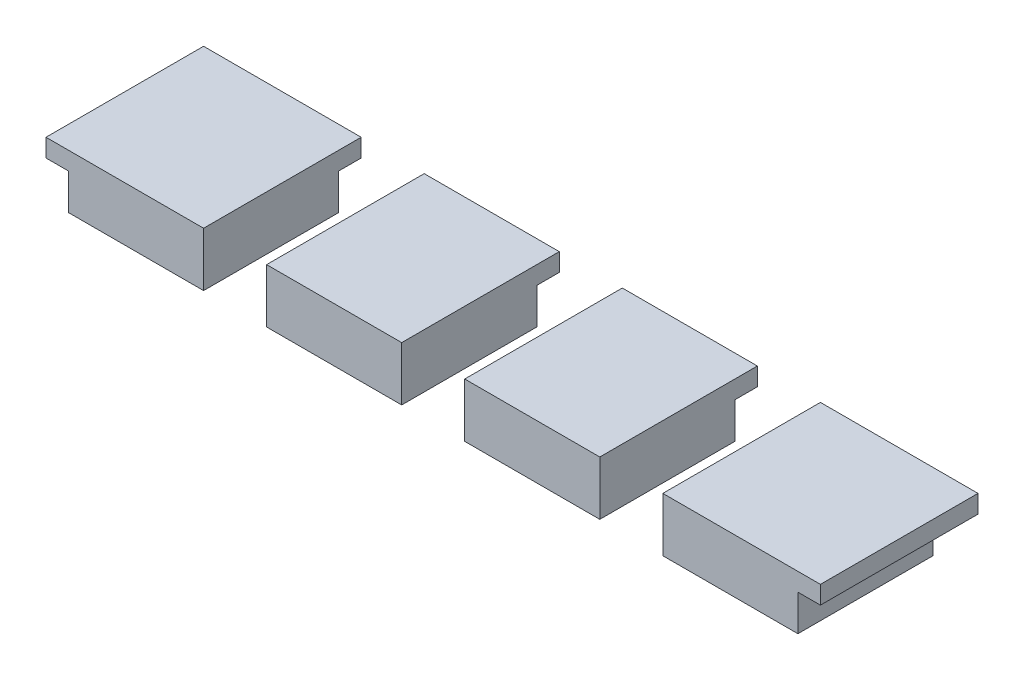
from build123d import *
from build123d.topology import SkipClean

# Parameters (mm, degrees)
SKETCH1_W                 = 78.1
SKETCH1_H                 = 55.9
BOSS_EXTRUDE1_DEPTH       = 3
SKETCH2_R                 = 1.25
CUT_EXTRUDE1_DEPTH        = 68
SKETCH4_W                 = 82.1
SKETCH4_H                 = 59.9
SKETCH4_W_2               = 78.1
SKETCH4_H_2               = 55.9
BOSS_EXTRUDE3_DEPTH       = 3
SKETCH6_R                 = 3
SKETCH6_R_2               = 1.25
BOSS_EXTRUDE4_DEPTH       = 3.5
SKETCH7_W                 = 82.1
SKETCH7_H                 = 16.2
BOSS_EXTRUDE5_DEPTH       = 3
SKETCH8_W                 = 82.1
SKETCH8_H                 = 50.5
BOSS_EXTRUDE6_DEPTH       = 3
SKETCH10_W                = 76.1
SKETCH10_H                = 3
BOSS_EXTRUDE7_DEPTH       = 20
SKETCH12_W                = 79.1
SKETCH12_H                = 50.5
BOSS_EXTRUDE8_DEPTH       = 3
SKETCH17_W                = 105.1
SKETCH17_H                = 50.5
BOSS_EXTRUDE13_DEPTH      = 1
BOSS_EXTRUDE13_DEPTH_BACK = 2
SKETCH18_W                = 11.5
SKETCH18_H                = 7.7
SKETCH18_W_2              = 39.6
SKETCH18_H_2              = 9
CUT_EXTRUDE4_DEPTH        = 9
SKETCH19_W                = 80.1
SKETCH19_H                = 50.5
BOSS_EXTRUDE14_DEPTH      = 3
SKETCH20_R                = 19
SKETCH20_R_2              = 1.5
CUT_EXTRUDE5_DEPTH        = 3
SKETCH22_R                = 2.5
CUT_EXTRUDE6_DEPTH        = 3
SKETCH23_R                = 1.5
BOSS_EXTRUDE16_DEPTH      = 3
SKETCH25_W                = 108.1
SKETCH25_H                = 50.5
CUT_EXTRUDE8_DEPTH        = 0.5
SKETCH26_W                = 79.6
SKETCH26_H                = 50.5
CUT_EXTRUDE9_DEPTH        = 0.5
SKETCH27_W                = 107.6
SKETCH27_H                = 50.5
CUT_EXTRUDE10_DEPTH       = 0.5
SKETCH28_W                = 79.1
SKETCH28_H                = 50.5
CUT_EXTRUDE11_DEPTH       = 0.5
SKETCH30_W                = 101.1
SKETCH30_H                = 73.1
BOSS_EXTRUDE17_DEPTH      = 2
BOSS_EXTRUDE17_DEPTH_BACK = 6
SKETCH31_W                = 39.6
SKETCH31_H                = 15.2
CUT_EXTRUDE12_DEPTH       = 18
SKETCH32_R                = 4
CUT_EXTRUDE13_DEPTH       = 788
SKETCH35_W                = 128.237297138
SKETCH35_H                = 101.417338931
CUT_EXTRUDE16_DEPTH       = 109
SKETCH36_W                = 107.1
SKETCH36_H                = 79.1
SKETCH36_W_2              = 102.1
SKETCH36_H_2              = 74.1
BOSS_EXTRUDE18_DEPTH      = 2
SKETCH37_W                = 107.1
SKETCH37_H                = 79.1
SKETCH37_W_2              = 102.1
SKETCH37_H_2              = 74.1
CUT_EXTRUDE17_DEPTH       = 6
SKETCH38_W                = 102.1
SKETCH38_H                = 74.1
SKETCH38_W_2              = 42.302719986
SKETCH38_H_2              = 18.764227688
BOSS_EXTRUDE19_DEPTH      = 2
SKETCH39_W                = 98.1
SKETCH39_H                = 70.1
CUT_EXTRUDE18_DEPTH       = 6
SKETCH40_R                = 4
BOSS_EXTRUDE21_DEPTH      = 20
SKETCH43_W                = 43.5
SKETCH43_H                = 1.5
CUT_EXTRUDE19_DEPTH       = 20
SKETCH44_W                = 22
SKETCH44_H                = 1.5
CUT_EXTRUDE20_DEPTH       = 20
FILLET1_R                 = 3
SKETCH45_W                = 73.258832398
SKETCH45_H                = 44.668177242
CUT_EXTRUDE21_DEPTH       = 63
CUT_EXTRUDE22_DEPTH       = 380
CUT_EXTRUDE22_DEPTH_BACK  = 374
BOSS_EXTRUDE23_DEPTH      = 2
SKETCH50_R                = 4
BOSS_EXTRUDE24_DEPTH      = 23
FILLET2_R                 = 3
SKETCH51_W                = 22
SKETCH51_H                = 0.5
CUT_EXTRUDE23_DEPTH       = 23
SKETCH52_W                = 22
SKETCH52_H                = 0.5
CUT_EXTRUDE24_DEPTH       = 23
SKETCH53_W                = 8
SKETCH53_H                = 8
CUT_EXTRUDE25_DEPTH       = 23
CUT_EXTRUDE26_DEPTH       = 23
SKETCH56_W                = 3.4
SKETCH56_H                = 1.5
SKETCH56_H_2              = 8
BOSS_EXTRUDE25_DEPTH      = 6
SKETCH58_W                = 4.9
SKETCH58_H                = 11
BOSS_EXTRUDE26_DEPTH      = 6
SKETCH61_R                = 1
CUT_EXTRUDE27_DEPTH       = 6
SKETCH62_W                = 3.4
SKETCH62_H                = 15.6
BOSS_EXTRUDE27_DEPTH      = 6
SKETCH64_W                = 4.9
SKETCH64_H                = 11
SKETCH64_R                = 1
SKETCH64_W_2              = 1.5
SKETCH64_H_2              = 70.1
BOSS_EXTRUDE28_DEPTH      = 2
BOSS_EXTRUDE29_DEPTH      = 8
SKETCH67_W                = 107.1
SKETCH67_H                = 79.1
SKETCH67_R                = 4
SKETCH67_W_2              = 8
SKETCH67_H_2              = 8
BOSS_EXTRUDE30_DEPTH      = 22
SKETCH68_W                = 8.1
SKETCH68_H                = 59.1
CUT_EXTRUDE28_DEPTH       = 22
SKETCH70_R                = 1.25
CUT_EXTRUDE29_DEPTH       = 22
SKETCH71_W                = 63
SKETCH71_H                = 13
CUT_EXTRUDE30_DEPTH       = 22
SKETCH72_W                = 72.2
SKETCH72_H                = 25
CUT_EXTRUDE31_DEPTH       = 1
SKETCH73_R                = 2.930769111
SKETCH73_R_2              = 1.25
SKETCH73_R_3              = 2.93
SKETCH73_W                = 75
SKETCH73_H                = 27.649527195
SKETCH73_W_2              = 72.2
SKETCH73_H_2              = 25
BOSS_EXTRUDE31_DEPTH      = 3
SKETCH74_R                = 2.93
SKETCH74_R_2              = 1.25
SKETCH74_R_3              = 2.930769111
BOSS_EXTRUDE32_DEPTH      = 3.5
SKETCH75_W                = 41
SKETCH75_H                = 1.5
BOSS_EXTRUDE33_DEPTH      = 22
SKETCH76_R                = 1.25
BOSS_EXTRUDE34_DEPTH      = 2
SKETCH78_W                = 107.1
SKETCH78_H                = 79.1
SKETCH78_W_2              = 101.1
SKETCH78_H_2              = 73.1
CUT_EXTRUDE32_DEPTH       = 22
SKETCH79_W                = 20.5
SKETCH79_H                = 1.5
CUT_EXTRUDE33_DEPTH       = 22
SKETCH80_W                = 77.6
SKETCH80_H                = 1.5
SKETCH80_R                = 1
SKETCH80_W_2              = 4.9
SKETCH80_H_2              = 26.6
CUT_EXTRUDE34_DEPTH       = 22
SKETCH81_R                = 1
CUT_EXTRUDE35_DEPTH       = 22
SKETCH82_W                = 41
SKETCH82_H                = 11
CUT_EXTRUDE36_DEPTH       = 22
SKETCH85_R                = 1.25
CUT_EXTRUDE38_DEPTH       = 9
SKETCH86_R                = 1.25
CUT_EXTRUDE39_DEPTH       = 9
SKETCH88_W                = 20.5
SKETCH88_H                = 1.5
BOSS_EXTRUDE35_DEPTH      = 4
SKETCH89_W                = 4.9
SKETCH89_H                = 45
BOSS_EXTRUDE36_DEPTH      = 9
SKETCH90_W                = 4.9
SKETCH90_H                = 73.1
BOSS_EXTRUDE37_DEPTH      = 9
SKETCH91_R                = 1.25
CUT_EXTRUDE41_DEPTH       = 9
SKETCH92_W                = 61.396361311
SKETCH92_H                = 8
BOSS_EXTRUDE38_DEPTH      = 4.9
SKETCH94_R                = 1.25
CUT_EXTRUDE42_DEPTH       = 4.9
SKETCH96_R                = 1.25
CUT_EXTRUDE43_DEPTH       = 9.9
SKETCH97_R                = 1.25
CUT_EXTRUDE44_DEPTH       = 9.9
SKETCH98_W                = 202.561194078
SKETCH98_H                = 189.268838742
CUT_EXTRUDE45_DEPTH       = 104
SKETCH99_W                = 174.962002929
SKETCH99_H                = 136.68810235
SKETCH99_W_2              = 43
SKETCH99_H_2              = 8
CUT_EXTRUDE47_DEPTH       = 104
SKETCH100_W               = 7.5
SKETCH100_H               = 7.5
BOSS_EXTRUDE41_DEPTH      = 2
BOSS_EXTRUDE41_2_DEPTH    = 2
BOSS_EXTRUDE41_3_DEPTH    = 2
BOSS_EXTRUDE41_4_DEPTH    = 2
SKETCH105_W               = 43
SKETCH105_H               = 2
CUT_EXTRUDE50_DEPTH       = 18
SKETCH106_W               = 7.5
SKETCH106_H               = 2.75
SKETCH106_H_2             = 2
SKETCH106_W_2             = 3.5
BOSS_EXTRUDE42_DEPTH      = 1
SKETCH107_W               = 8.75
SKETCH107_H               = 1.25
SKETCH107_W_2             = 7.5
SKETCH107_W_3             = 7.684755435
BOSS_EXTRUDE43_DEPTH      = 1
SKETCH108_W               = 0.184755435
SKETCH108_H               = 1.25
CUT_EXTRUDE51_DEPTH       = 1
SKETCH110_W               = 3.5
SKETCH110_H               = 2
CUT_EXTRUDE52_DEPTH       = 10


with BuildPart() as part:
    # Sketch1 → Boss-Extrude1 (new body)
    with BuildSketch(Plane(origin=(0, 0, 0), x_dir=(1, 0, 0), z_dir=(0, 1, 0))):
        Rectangle(SKETCH1_W, SKETCH1_H)
    extrude(amount=BOSS_EXTRUDE1_DEPTH)

    # Sketch2 → Cut-Extrude1 (cut)
    with BuildSketch(Plane(origin=(0, 3, 0), x_dir=(1, 0, 0), z_dir=(0, 1, 0))):
        with Locations(Location((-35.9, 20.9, 0), (0, 0, 270))):
            Circle(SKETCH2_R)
        with Locations(Location((-35.9, -24.8, 0), (0, 0, 270))):
            Circle(SKETCH2_R)
        with Locations(Location((35.9, -24.8, 0), (0, 0, 270))):
            Circle(SKETCH2_R)
        with Locations(Location((35.9, 24.8, 0), (0, 0, 270))):
            Circle(SKETCH2_R)
    extrude(amount=-CUT_EXTRUDE1_DEPTH, mode=Mode.SUBTRACT)

    # Sketch4 → Boss-Extrude3 (add)
    with BuildSketch(Plane(origin=(0, 0, 0), x_dir=(-1, 0, 0), z_dir=(0, -1, 0))):
        Rectangle(SKETCH4_W, SKETCH4_H)
        Rectangle(SKETCH4_W_2, SKETCH4_H_2, mode=Mode.SUBTRACT)
    extrude(amount=-BOSS_EXTRUDE3_DEPTH)

    # Sketch6 → Boss-Extrude4 (add)
    with BuildSketch(Plane(origin=(0, 3, 0), x_dir=(1, 0, 0), z_dir=(0, 1, 0))):
        with Locations(Location((-35.9, 20.9, 0), (0, 0, 90))):
            Circle(SKETCH6_R)
        with Locations(Location((-35.9, 20.9, 0), (0, 0, 270))):
            Circle(SKETCH6_R_2, mode=Mode.SUBTRACT)
        with Locations(Location((35.9, 24.8, 0), (0, 0, 90))):
            Circle(SKETCH6_R)
        with Locations(Location((35.9, 24.8, 0), (0, 0, 270))):
            Circle(SKETCH6_R_2, mode=Mode.SUBTRACT)
        with Locations(Location((35.9, -24.8, 0), (0, 0, 90))):
            Circle(SKETCH6_R)
        with Locations(Location((35.9, -24.8, 0), (0, 0, 270))):
            Circle(SKETCH6_R_2, mode=Mode.SUBTRACT)
        with Locations(Location((-35.9, -24.8, 0), (0, 0, 90))):
            Circle(SKETCH6_R)
        with Locations(Location((-35.9, -24.8, 0), (0, 0, 270))):
            Circle(SKETCH6_R_2, mode=Mode.SUBTRACT)
    extrude(amount=BOSS_EXTRUDE4_DEPTH)

    # Sketch7 → Boss-Extrude5 (add)
    with BuildSketch(Plane(origin=(0, 0, 0), x_dir=(-1, 0, 0), z_dir=(0, -1, 0))):
        with Locations((0, 38.05)):
            Rectangle(SKETCH7_W, SKETCH7_H)
    extrude(amount=-BOSS_EXTRUDE5_DEPTH)

    # Sketch8 → Boss-Extrude6 (add)
    with BuildSketch(Plane(origin=(0, 0, -46.15), x_dir=(-1, 0, 0), z_dir=(0, 0, -1))):
        with Locations((0, 25.25)):
            Rectangle(SKETCH8_W, SKETCH8_H)
    extrude(amount=BOSS_EXTRUDE6_DEPTH)

    # Sketch10 → Boss-Extrude7 (add)
    with BuildSketch(Plane(origin=(41.05, 0, 0), x_dir=(0, 0, -1), z_dir=(1, 0, 0))):
        Polygon((49.15, 50.5), (46.15, 50.5), (46.15, 3), (46.15, 0), (49.15, 0), align=None)
        with Locations((8.1, 1.5)):
            Rectangle(SKETCH10_W, SKETCH10_H)
    extrude(amount=BOSS_EXTRUDE7_DEPTH)

    # Sketch12 → Boss-Extrude8 (add)
    with BuildSketch(Plane.ZY.offset(41.05)):
        with Locations((-9.6, 25.25)):
            Rectangle(SKETCH12_W, SKETCH12_H)
    extrude(amount=BOSS_EXTRUDE8_DEPTH)

    # Sketch17 → Boss-Extrude13 (add, two sides)
    with BuildSketch(Plane.XY.offset(29.95)) as boss_extrude13_sk:
        with Locations((8.5, 25.25)):
            Rectangle(SKETCH17_W, SKETCH17_H)
    extrude(amount=BOSS_EXTRUDE13_DEPTH)
    extrude(boss_extrude13_sk.sketch, amount=-BOSS_EXTRUDE13_DEPTH_BACK)

    # Sketch18 → Cut-Extrude4 (cut)
    with BuildSketch(Plane(origin=(0, 0, 27.95), x_dir=(-1, 0, 0), z_dir=(0, 0, -1))):
        with Locations((-21.6, 9.95)):
            Rectangle(SKETCH18_W, SKETCH18_H)
        with Locations((11.35, 17.6)):
            Rectangle(SKETCH18_W_2, SKETCH18_H_2)
    extrude(amount=-CUT_EXTRUDE4_DEPTH, mode=Mode.SUBTRACT)

    # Sketch19 → Boss-Extrude14 (add)
    with BuildSketch(Plane(origin=(61.05, 0, 0), x_dir=(0, 0, -1), z_dir=(1, 0, 0))):
        with Locations((9.1, 25.25)):
            Rectangle(SKETCH19_W, SKETCH19_H)
    extrude(amount=BOSS_EXTRUDE14_DEPTH)

    # Sketch20 → Cut-Extrude5 (cut)
    with BuildSketch(Plane.ZY.offset(-61.05)):
        with Locations((-24.15, 25)):
            Circle(SKETCH20_R)
        with Locations((-8.4, 40.75)):
            Circle(SKETCH20_R_2)
        with Locations((-39.9, 40.75)):
            Circle(SKETCH20_R_2)
        with Locations((-8.4, 9.25)):
            Circle(SKETCH20_R_2)
        with Locations((-39.9, 9.25)):
            Circle(SKETCH20_R_2)
    extrude(amount=-CUT_EXTRUDE5_DEPTH, mode=Mode.SUBTRACT)

    # Sketch22 → Cut-Extrude6 (cut)
    with BuildSketch(Plane(origin=(-41.05, 0, 0), x_dir=(0, 0, -1), z_dir=(1, 0, 0))):
        with Locations((14.225, 12.6875)):
            Circle(SKETCH22_R)
        with Locations((14.225, 22.0625)):
            Circle(SKETCH22_R)
        with Locations((18.5, 17.375)):
            Circle(SKETCH22_R)
        with Locations((22.775, 22.0625)):
            Circle(SKETCH22_R)
        with Locations((22.775, 12.6875)):
            Circle(SKETCH22_R)
        with Locations((14.225, 31.4375)):
            Circle(SKETCH22_R)
        with Locations((18.5, 26.75)):
            Circle(SKETCH22_R)
        with Locations((22.775, 31.4375)):
            Circle(SKETCH22_R)
        with Locations((18.5, 36.125)):
            Circle(SKETCH22_R)
        with Locations((14.225, 40.8125)):
            Circle(SKETCH22_R)
        with Locations((22.775, 40.8125)):
            Circle(SKETCH22_R)
        with Locations((27.05, 36.125)):
            Circle(SKETCH22_R)
        with Locations((31.325, 40.8125)):
            Circle(SKETCH22_R)
        with Locations((39.875, 40.8125)):
            Circle(SKETCH22_R)
        with Locations((35.6, 36.125)):
            Circle(SKETCH22_R)
        with Locations((39.875, 31.4375)):
            Circle(SKETCH22_R)
        with Locations((31.325, 31.4375)):
            Circle(SKETCH22_R)
        with Locations((27.05, 26.75)):
            Circle(SKETCH22_R)
        with Locations((31.325, 22.0625)):
            Circle(SKETCH22_R)
        with Locations((39.875, 22.0625)):
            Circle(SKETCH22_R)
        with Locations((35.6, 26.75)):
            Circle(SKETCH22_R)
        with Locations((27.05, 17.375)):
            Circle(SKETCH22_R)
        with Locations((31.325, 12.6875)):
            Circle(SKETCH22_R)
        with Locations((39.875, 12.6875)):
            Circle(SKETCH22_R)
        with Locations((35.6, 17.375)):
            Circle(SKETCH22_R)
        with Locations((18.5, 8)):
            Circle(SKETCH22_R)
        with Locations((27.05, 8)):
            Circle(SKETCH22_R)
        with Locations((35.6, 8)):
            Circle(SKETCH22_R)
    extrude(amount=-CUT_EXTRUDE6_DEPTH, mode=Mode.SUBTRACT)

    # Sketch23 → Boss-Extrude16 (add)
    with BuildSketch(Plane(origin=(64.05, 0, 0), x_dir=(0, 0, -1), z_dir=(1, 0, 0))):
        with Locations((8.4, 9.25)):
            Circle(SKETCH23_R)
        with Locations((39.9, 40.75)):
            Circle(SKETCH23_R)
    extrude(amount=-BOSS_EXTRUDE16_DEPTH)

    # Sketch25 → Cut-Extrude8 (cut)
    with BuildSketch(Plane.XY.offset(30.95)):
        with Locations((10, 25.25)):
            Rectangle(SKETCH25_W, SKETCH25_H)
    extrude(amount=-CUT_EXTRUDE8_DEPTH, mode=Mode.SUBTRACT)

    # Sketch26 → Cut-Extrude9 (cut)
    with BuildSketch(Plane(origin=(64.05, 0, 0), x_dir=(0, 0, -1), z_dir=(1, 0, 0))):
        with Locations((9.35, 25.25)):
            Rectangle(SKETCH26_W, SKETCH26_H)
    extrude(amount=-CUT_EXTRUDE9_DEPTH, mode=Mode.SUBTRACT)

    # Sketch27 → Cut-Extrude10 (cut)
    with BuildSketch(Plane(origin=(0, 0, -49.15), x_dir=(-1, 0, 0), z_dir=(0, 0, -1))):
        with Locations((-9.75, 25.25)):
            Rectangle(SKETCH27_W, SKETCH27_H)
    extrude(amount=-CUT_EXTRUDE10_DEPTH, mode=Mode.SUBTRACT)

    # Sketch28 → Cut-Extrude11 (cut)
    with BuildSketch(Plane.ZY.offset(44.05)):
        with Locations((-9.1, 25.25)):
            Rectangle(SKETCH28_W, SKETCH28_H)
    extrude(amount=-CUT_EXTRUDE11_DEPTH, mode=Mode.SUBTRACT)

    # Sketch31 → Cut-Extrude12 (cut)
    with BuildSketch(Plane(origin=(0, 3, 0), x_dir=(1, 0, 0), z_dir=(0, 1, 0))):
        with Locations((-11.35, -20.35)):
            Rectangle(SKETCH31_W, SKETCH31_H)
    extrude(amount=-CUT_EXTRUDE12_DEPTH, mode=Mode.SUBTRACT)


with BuildPart() as body_2:
    # Sketch30 → Boss-Extrude17 (new, two sides)
    with BuildSketch(Plane(origin=(0, 50.5, 0), x_dir=(1, 0, 0), z_dir=(0, 1, 0))) as boss_extrude17_sk:
        with Locations((10, 9.1)):
            Rectangle(SKETCH30_W, SKETCH30_H)
    extrude(amount=BOSS_EXTRUDE17_DEPTH)
    extrude(boss_extrude17_sk.sketch, amount=-BOSS_EXTRUDE17_DEPTH_BACK)


with BuildPart() as cut_extrude13_tool:
    # Sketch32 → Cut-Extrude13 (new body)
    with BuildSketch(Plane.XZ):
        with Locations(Location((2.73, 16.581093047, 0), (0, 0, 270))):
            Circle(SKETCH32_R)
        with Locations(Location((-6.607184449, 16.581093047, 0), (0, 0, 270))):
            Circle(SKETCH32_R)
        with Locations(Location((-16.03, 16.55, 0), (0, 0, 270))):
            Circle(SKETCH32_R)
        with Locations(Location((-25.43, 16.55, 0), (0, 0, 270))):
            Circle(SKETCH32_R)
    extrude(amount=-CUT_EXTRUDE13_DEPTH)


with BuildPart() as part_1:
    add(part.part)

    # Cut-Extrude13: cut by cut_extrude13_tool
    add(cut_extrude13_tool.part, mode=Mode.SUBTRACT)

    # Sketch35 → Cut-Extrude16 (cut)
    with BuildSketch(Plane.XY.offset(30.45)):
        with Locations((20.568648569, -6.208669466)):
            Rectangle(SKETCH35_W, SKETCH35_H)
    extrude(amount=-CUT_EXTRUDE16_DEPTH, mode=Mode.SUBTRACT)

    # Sketch36 → Boss-Extrude18 (add)
    with BuildSketch(Plane(origin=(0, 50.5, 0), x_dir=(1, 0, 0), z_dir=(0, 1, 0))):
        with Locations((10, 9.1)):
            Rectangle(SKETCH36_W, SKETCH36_H)
        with Locations((10, 9.1)):
            Rectangle(SKETCH36_W_2, SKETCH36_H_2, mode=Mode.SUBTRACT)
    extrude(amount=BOSS_EXTRUDE18_DEPTH)

    # Sketch37 → Cut-Extrude17 (cut)
    with BuildSketch(Plane(origin=(0, 44.5, 0), x_dir=(-1, 0, 0), z_dir=(0, -1, 0))):
        with Locations((-10, 9.1)):
            Rectangle(SKETCH37_W, SKETCH37_H)
        with Locations((-10, 9.1)):
            Rectangle(SKETCH37_W_2, SKETCH37_H_2, mode=Mode.SUBTRACT)
    extrude(amount=-CUT_EXTRUDE17_DEPTH, mode=Mode.SUBTRACT)



with BuildPart() as body_2_1:
    add(body_2.part)

    # Cut-Extrude13: cut by cut_extrude13_tool
    add(cut_extrude13_tool.part, mode=Mode.SUBTRACT)


with BuildPart() as part_2:
    add(part_1.part)

    add(body_2_1.part)  # Boss-Extrude19 merges body 2
    # Sketch38 → Boss-Extrude19 (add)
    with BuildSketch(Plane(origin=(0, 52.5, 0), x_dir=(1, 0, 0), z_dir=(0, 1, 0))):
        with Locations((10, 9.1)):
            Rectangle(SKETCH38_W, SKETCH38_H)
        with Locations((-11.151359993, -15.547609528)):
            Rectangle(SKETCH38_W_2, SKETCH38_H_2, mode=Mode.SUBTRACT)
    extrude(amount=-BOSS_EXTRUDE19_DEPTH)

    # Sketch39 → Cut-Extrude18 (cut)
    with BuildSketch(Plane(origin=(0, 44.5, 0), x_dir=(-1, 0, 0), z_dir=(0, -1, 0))):
        with Locations((-10, 9.1)):
            Rectangle(SKETCH39_W, SKETCH39_H)
    extrude(amount=-CUT_EXTRUDE18_DEPTH, mode=Mode.SUBTRACT)

    # Sketch40 → Boss-Extrude21 (add)
    with BuildSketch(Plane(origin=(0, 50.5, 0), x_dir=(-1, 0, 0), z_dir=(0, -1, 0))):
        with BuildLine():
            Line((25.43, -11.181722504), (-2.73, -11.243908599))
            ThreePointArc((-2.73, -11.243908599), (-8.067184449, -16.581093047), (-2.73, -21.918277496))
            Line((-2.73, -21.918277496), (25.43, -21.918277496))
            ThreePointArc((25.43, -21.918277496), (30.798277496, -16.55), (25.43, -11.181722504))
        make_face()
        with Locations(Location((6.607184449, -16.581093047, 0), (0, 0, 90))):
            Circle(SKETCH40_R, mode=Mode.SUBTRACT)
        with Locations(Location((16.03, -16.55, 0), (0, 0, 90))):
            Circle(SKETCH40_R, mode=Mode.SUBTRACT)
        with Locations(Location((25.43, -16.55, 0), (0, 0, 90))):
            Circle(SKETCH40_R, mode=Mode.SUBTRACT)
        with Locations(Location((-2.73, -16.581093047, 0), (0, 0, 90))):
            Circle(SKETCH40_R, mode=Mode.SUBTRACT)
    extrude(amount=BOSS_EXTRUDE21_DEPTH)

    # Sketch43 → Cut-Extrude19 (cut)
    with BuildSketch(Plane.ZY.offset(-59.05)):
        with Locations((-22.4, 45.25)):
            Rectangle(SKETCH43_W, SKETCH43_H)
    extrude(amount=-CUT_EXTRUDE19_DEPTH, mode=Mode.SUBTRACT)

    # Sketch44 → Cut-Extrude20 (cut)
    with BuildSketch(Plane.XY.offset(-44.15)):
        with Locations((49.55, 45.25)):
            Rectangle(SKETCH44_W, SKETCH44_H)
    extrude(amount=-CUT_EXTRUDE20_DEPTH, mode=Mode.SUBTRACT)

    # Fillet1
    fillet1_edges = [part_2.edges().sort_by_distance(p)[0] for p in [
        (-11.35, 50.5, 21.918277496),
        (-30.798277496, 50.5, 16.55),
        (-11.35, 50.5, 11.212815551),
        (8.067184449, 50.5, 16.581093047),
    ]]
    fillet(fillet1_edges, radius=FILLET1_R)

    # Sketch45 → Cut-Extrude21 (cut)
    with BuildSketch(Plane(origin=(0, 50.5, 0), x_dir=(-1, 0, 0), z_dir=(0, -1, 0))):
        with Locations((2.420583801, -3.615911379)):
            Rectangle(SKETCH45_W, SKETCH45_H)
    extrude(amount=CUT_EXTRUDE21_DEPTH, mode=Mode.SUBTRACT)

    # Sketch3 → Cut-Extrude22 (cut, two sides)
    with BuildSketch(Plane(origin=(0, 3, 0), x_dir=(1, 0, 0), z_dir=(0, 1, 0))) as cut_extrude22_sk:
        with BuildLine():
            ThreePointArc((-21.45, -20.45), (-25.45, -16.45), (-29.45, -20.45))
            Line((-29.45, -20.45), (-25.45, -20.45))
            Line((-25.45, -20.45), (-21.45, -20.45))
        make_face()
        with BuildLine():
            ThreePointArc((-29.45, -20.45), (-28.278427125, -23.278427125), (-25.45, -24.45))
            Line((-25.45, -24.45), (-25.45, -20.45))
            Line((-25.45, -20.45), (-29.45, -20.45))
        make_face()
        with BuildLine():
            Line((-25.45, -20.45), (-25.45, -24.45))
            ThreePointArc((-25.45, -24.45), (-22.621572875, -23.278427125), (-21.45, -20.45))
            Line((-21.45, -20.45), (-25.45, -20.45))
        make_face()
        with BuildLine():
            ThreePointArc((-20.05, -20.45), (-18.878427125, -23.278427125), (-16.05, -24.45))
            Line((-16.05, -24.45), (-16.05, -20.45))
            Line((-16.05, -20.45), (-20.05, -20.45))
        make_face()
        with BuildLine():
            Line((-16.05, -20.45), (-16.05, -24.45))
            ThreePointArc((-16.05, -24.45), (-13.221572875, -23.278427125), (-12.05, -20.45))
            ThreePointArc((-12.05, -20.45), (-16.05, -16.45), (-20.05, -20.45))
            Line((-20.05, -20.45), (-16.05, -20.45))
        make_face()
        with BuildLine():
            ThreePointArc((-2.65, -20.45), (-9.478427125, -17.621572875), (-6.65, -24.45))
            Line((-6.65, -24.45), (-6.65, -20.45))
            Line((-6.65, -20.45), (-2.65, -20.45))
        make_face()
        with BuildLine():
            Line((-6.65, -20.45), (-6.65, -24.45))
            ThreePointArc((-6.65, -24.45), (-3.821572875, -23.278427125), (-2.65, -20.45))
            Line((-2.65, -20.45), (-6.65, -20.45))
        make_face()
        with BuildLine():
            ThreePointArc((-1.25, -20.45), (-0.078427125, -23.278427125), (2.75, -24.45))
            Line((2.75, -24.45), (2.75, -20.45))
            Line((2.75, -20.45), (-1.25, -20.45))
        make_face()
        with BuildLine():
            Line((2.75, -20.45), (2.75, -24.45))
            ThreePointArc((2.75, -24.45), (5.578427125, -23.278427125), (6.75, -20.45))
            Line((6.75, -20.45), (2.75, -20.45))
        make_face()
        with BuildLine():
            Line((2.75, -20.45), (6.75, -20.45))
            ThreePointArc((6.75, -20.45), (2.75, -16.45), (-1.25, -20.45))
            Line((-1.25, -20.45), (2.75, -20.45))
        make_face()
    extrude(amount=CUT_EXTRUDE22_DEPTH, mode=Mode.SUBTRACT)
    extrude(cut_extrude22_sk.sketch, amount=-CUT_EXTRUDE22_DEPTH_BACK, mode=Mode.SUBTRACT)

    # Sketch49 → Boss-Extrude23 (add)
    with BuildSketch(Plane(origin=(0, 50.5, 0), x_dir=(-1, 0, 0), z_dir=(0, -1, 0))):
        with BuildLine():
            ThreePointArc((-6.241065865, -18.497448048), (-2.729322601, -16.450053445), (0.761065865, -18.533644999))
            ThreePointArc((0.761065865, -18.533644999), (1.140675875, -17.589987625), (1.27, -16.581093047))
            ThreePointArc((1.27, -16.581093047), (-3.718872221, -12.70525356), (-6.241065865, -18.497448048))
        make_face()
        with BuildLine():
            ThreePointArc((3.127745115, -18.554288913), (6.605736408, -16.450244916), (10.129439334, -18.476804135))
            ThreePointArc((10.129439334, -18.476804135), (10.485909725, -17.558584853), (10.607184449, -16.581093047))
            ThreePointArc((10.607184449, -16.581093047), (5.586830916, -12.713422086), (3.127745115, -18.554288913))
        make_face()
        with BuildLine():
            ThreePointArc((12.547568292, -18.517909906), (16.029487449, -16.450052596), (19.532431708, -18.482090094))
            ThreePointArc((19.532431708, -18.482090094), (19.90361116, -17.547565328), (20.03, -16.55))
            ThreePointArc((20.03, -16.55), (15.012583377, -12.681555427), (12.547568292, -18.517909906))
        make_face()
        with BuildLine():
            ThreePointArc((21.947568292, -18.517909906), (25.429487449, -16.450052596), (28.932431708, -18.482090094))
            ThreePointArc((28.932431708, -18.482090094), (29.30361116, -17.547565328), (29.43, -16.55))
            ThreePointArc((29.43, -16.55), (24.412583377, -12.681555427), (21.947568292, -18.517909906))
        make_face()
    extrude(amount=-BOSS_EXTRUDE23_DEPTH)

    # Sketch50 → Boss-Extrude24 (add)
    with SkipClean():  # the faces are left unmerged after this step: merging them gives an invalid solid
        with BuildSketch(Plane(origin=(0, 50.5, 0), x_dir=(-1, 0, 0), z_dir=(0, -1, 0))):
            with BuildLine():
                Line((-2.75, -25.95), (25.45, -25.95))
                ThreePointArc((25.45, -25.95), (30.95, -20.45), (25.45, -14.95))
                Line((25.45, -14.95), (-2.75, -14.95))
                ThreePointArc((-2.75, -14.95), (-8.25, -20.45), (-2.75, -25.95))
            make_face()
            with Locations(Location((16.05, -20.45, 0), (0, 0, 90))):
                Circle(SKETCH50_R, mode=Mode.SUBTRACT)
            with Locations(Location((6.65, -20.45, 0), (0, 0, 90))):
                Circle(SKETCH50_R, mode=Mode.SUBTRACT)
            with Locations(Location((25.45, -20.45, 0), (0, 0, 90))):
                Circle(SKETCH50_R, mode=Mode.SUBTRACT)
            with Locations(Location((-2.75, -20.45, 0), (0, 0, 90))):
                Circle(SKETCH50_R, mode=Mode.SUBTRACT)
        extrude(amount=BOSS_EXTRUDE24_DEPTH)

    # Fillet2
    fillet2_edges = [part_2.edges().sort_by_distance(p)[0] for p in [
        (-11.35, 50.5, 14.95),
        (8.25, 50.5, 20.45),
        (-30.95, 50.5, 20.45),
    ]]
    fillet(fillet2_edges, radius=FILLET2_R)

    # Sketch51 → Cut-Extrude23 (cut)
    with SkipClean():  # the faces are left unmerged after this step: merging them gives an invalid solid
        with BuildSketch(Plane(origin=(0, 0, -45.65), x_dir=(-1, 0, 0), z_dir=(0, 0, -1))):
            with Locations((-49.55, 46.25)):
                Rectangle(SKETCH51_W, SKETCH51_H)
        extrude(amount=-CUT_EXTRUDE23_DEPTH, mode=Mode.SUBTRACT)

    # Sketch52 → Cut-Extrude24 (cut)
    with SkipClean():  # the faces are left unmerged after this step: merging them gives an invalid solid
        with BuildSketch(Plane(origin=(60.55, 0, 0), x_dir=(0, 0, -1), z_dir=(1, 0, 0))):
            with Locations((11.65, 46.25)):
                Rectangle(SKETCH52_W, SKETCH52_H)
        extrude(amount=-CUT_EXTRUDE24_DEPTH, mode=Mode.SUBTRACT)

    # Sketch53 → Cut-Extrude25 (cut)
    with SkipClean():  # the faces are left unmerged after this step: merging them gives an invalid solid
        with BuildSketch(Plane(origin=(0, 52.5, 0), x_dir=(1, 0, 0), z_dir=(0, 1, 0))):
            with Locations((51.65, -20.45)):
                Rectangle(SKETCH53_W, SKETCH53_H)
            with Locations((40.65, -20.45)):
                Rectangle(SKETCH53_W, SKETCH53_H)
            with Locations((29.65, -20.45)):
                Rectangle(SKETCH53_W, SKETCH53_H)
            with Locations((18.65, -20.45)):
                Rectangle(SKETCH53_W, SKETCH53_H)
        extrude(amount=-CUT_EXTRUDE25_DEPTH, mode=Mode.SUBTRACT)

    # Sketch54 → Cut-Extrude26 (cut)
    with SkipClean():  # the faces are left unmerged after this step: merging them gives an invalid solid
        with BuildSketch(Plane(origin=(0, 27.5, 0), x_dir=(-1, 0, 0), z_dir=(0, -1, 0))):
            Polygon((-14.201290386, -14.95), (-2.75, -14.95), (25.45, -14.95), (35.501290386, -14.95), (35.501290386, -4.067232411), (-14.201290386, -4.067232411), align=None)
            with BuildLine():
                Line((35.501290386, -14.95), (25.45, -14.95))
                ThreePointArc((25.45, -14.95), (29.339087297, -16.560912703), (30.95, -20.45))
                ThreePointArc((30.95, -20.45), (29.339087297, -24.339087297), (25.45, -25.95))
                Line((25.45, -25.95), (35.501290386, -25.95))
                Line((35.501290386, -25.95), (35.501290386, -14.95))
            make_face()
            with BuildLine():
                ThreePointArc((-2.75, -25.95), (-8.25, -20.45), (-2.75, -14.95))
                Line((-2.75, -14.95), (-14.201290386, -14.95))
                Line((-14.201290386, -14.95), (-14.201290386, -25.95))
                Line((-14.201290386, -25.95), (-2.75, -25.95))
            make_face()
        extrude(amount=-CUT_EXTRUDE26_DEPTH, mode=Mode.SUBTRACT)

    # Sketch56 → Boss-Extrude25 (add)
    with SkipClean():  # the faces are left unmerged after this step: merging them gives an invalid solid
        with BuildSketch(Plane.XZ.offset(-50.5)):
            with Locations((57.35, 25.2)):
                Rectangle(SKETCH56_W, SKETCH56_H)
            with Locations((57.35, 20.45)):
                Rectangle(SKETCH56_W, SKETCH56_H_2)
            with Locations((57.35, 15.7)):
                Rectangle(SKETCH56_W, SKETCH56_H)
        extrude(amount=BOSS_EXTRUDE25_DEPTH)

    # Sketch58 → Boss-Extrude26 (add)
    with SkipClean():  # the faces are left unmerged after this step: merging them gives an invalid solid
        with BuildSketch(Plane.XZ.offset(-50.5)):
            with Locations((12.2, 20.45)):
                Rectangle(SKETCH58_W, SKETCH58_H)
        extrude(amount=BOSS_EXTRUDE26_DEPTH)

    # Sketch61 → Cut-Extrude27 (cut)
    with SkipClean():  # the faces are left unmerged after this step: merging them gives an invalid solid
        with BuildSketch(Plane(origin=(0, 44.5, 0), x_dir=(-1, 0, 0), z_dir=(0, -1, 0))):
            with Locations(Location((-58.15, -20.45, 0), (0, 0, 90))):
                Circle(SKETCH61_R)
            with Locations(Location((-12.15, -20.45, 0), (0, 0, 90))):
                Circle(SKETCH61_R)
        extrude(amount=-CUT_EXTRUDE27_DEPTH, mode=Mode.SUBTRACT)

    # Sketch62 → Boss-Extrude27 (add)
    with SkipClean():  # the faces are left unmerged after this step: merging them gives an invalid solid
        with BuildSketch(Plane(origin=(0, 44.5, 0), x_dir=(-1, 0, 0), z_dir=(0, -1, 0))):
            with Locations((-57.35, -7.15)):
                Rectangle(SKETCH62_W, SKETCH62_H)
        extrude(amount=-BOSS_EXTRUDE27_DEPTH)

    # Sketch64 → Boss-Extrude28 (add)
    with BuildSketch(Plane.XZ.offset(-44.5)):
        with Locations((12.2, 20.45)):
            Rectangle(SKETCH64_W, SKETCH64_H)
        with Locations(Location((12.15, 20.45, 0), (0, 0, 270))):
            Circle(SKETCH64_R, mode=Mode.SUBTRACT)
        Polygon((55.65, 27.45), (55.65, 25.95), (55.65, -0.65), (60.55, -0.65), (60.55, 27.45), align=None)
        with Locations(Location((58.15, 20.45, 0), (0, 0, 270))):
            Circle(SKETCH64_R, mode=Mode.SUBTRACT)
        Polygon((2.75, 25.95), (9.75, 25.95), (14.65, 25.95), (55.65, 25.95), (55.65, 27.45), (-40.55, 27.45), (-40.55, 25.95), (-39.05, 25.95), (-25.45, 25.95), align=None)
        with Locations((-39.8, -9.1)):
            Rectangle(SKETCH64_W_2, SKETCH64_H_2)
        Polygon((38.55, -44.15), (-39.05, -44.15), (-40.55, -44.15), (-40.55, -45.65), (38.55, -45.65), align=None)
    extrude(amount=BOSS_EXTRUDE28_DEPTH)

    # Sketch65 → Boss-Extrude29 (add)
    with BuildSketch(Plane(origin=(0, 50.5, 0), x_dir=(-1, 0, 0), z_dir=(0, -1, 0))):
        with BuildLine():
            Line((-2.75, -14.95), (-9.75, -14.95))
            Line((-9.75, -14.95), (-9.75, -25.95))
            Line((-9.75, -25.95), (-2.75, -25.95))
            ThreePointArc((-2.75, -25.95), (-8.25, -20.45), (-2.75, -14.95))
        make_face()
    extrude(amount=BOSS_EXTRUDE29_DEPTH)

    # Sketch67 → Boss-Extrude30 (add)
    with BuildSketch(Plane(origin=(0, 52.5, 0), x_dir=(1, 0, 0), z_dir=(0, 1, 0))):
        with Locations((10, 9.1)):
            Rectangle(SKETCH67_W, SKETCH67_H)
        with Locations(Location((2.75, -20.45, 0), (0, 0, 90))):
            Circle(SKETCH67_R, mode=Mode.SUBTRACT)
        with Locations(Location((-6.65, -20.45, 0), (0, 0, 90))):
            Circle(SKETCH67_R, mode=Mode.SUBTRACT)
        with Locations(Location((-16.05, -20.45, 0), (0, 0, 90))):
            Circle(SKETCH67_R, mode=Mode.SUBTRACT)
        with Locations(Location((-25.45, -20.45, 0), (0, 0, 90))):
            Circle(SKETCH67_R, mode=Mode.SUBTRACT)
        with Locations((51.65, -20.45)):
            Rectangle(SKETCH67_W_2, SKETCH67_H_2, mode=Mode.SUBTRACT)
        with Locations((40.65, -20.45)):
            Rectangle(SKETCH67_W_2, SKETCH67_H_2, mode=Mode.SUBTRACT)
        with Locations((29.65, -20.45)):
            Rectangle(SKETCH67_W_2, SKETCH67_H_2, mode=Mode.SUBTRACT)
        with Locations((18.65, -20.45)):
            Rectangle(SKETCH67_W_2, SKETCH67_H_2, mode=Mode.SUBTRACT)
    extrude(amount=BOSS_EXTRUDE30_DEPTH)

    # Sketch68 → Cut-Extrude28 (cut)
    with BuildSketch(Plane.XZ.offset(-50.5)):
        Polygon((14.65, -44.15), (59.05, -44.15), (59.05, -0.65), (55.65, -0.65), (55.65, 16.45), (47.65, 16.45), (44.65, 16.45), (36.65, 16.45), (33.65, 16.45), (25.65, 16.45), (22.65, 16.45), (14.65, 16.45), (14.65, 14.95), align=None)
        Polygon((-30.95, -44.15), (14.65, -44.15), (14.65, 14.95), (-25.45, 14.95), (-30.95, 14.95), align=None)
        with Locations((-35, -14.6)):
            Rectangle(SKETCH68_W, SKETCH68_H)
        Polygon((-39.05, 14.95), (-30.95, 14.95), (-30.95, 20.450000012), (-30.95, 25.95), (-39.05, 25.95), align=None)
        with BuildLine():
            Line((-30.95, 14.95), (-25.45, 14.95))
            ThreePointArc((-25.45, 14.95), (-29.339087301, 16.560912708), (-30.95, 20.450000012))
            Line((-30.95, 20.450000012), (-30.95, 14.95))
        make_face()
        with BuildLine():
            Line((-30.95, 25.95), (-30.95, 20.450000012))
            ThreePointArc((-30.95, 20.450000012), (-29.339087292, 24.339087301), (-25.45, 25.95))
            Line((-25.45, 25.95), (-30.95, 25.95))
        make_face()
    extrude(amount=-CUT_EXTRUDE28_DEPTH, mode=Mode.SUBTRACT)

    # Sketch70 → Cut-Extrude29 (cut)
    with BuildSketch(Plane.XZ.offset(-72.5)):
        with Locations(Location((47.5, -31.1, 0), (0, 0, 270))):
            Circle(SKETCH70_R)
        with Locations(Location((-27.5, -31.1, 0), (0, 0, 270))):
            Circle(SKETCH70_R)
        with Locations(Location((-27.5, -0.1, 0), (0, 0, 270))):
            Circle(SKETCH70_R)
        with Locations(Location((47.5, -0.1, 0), (0, 0, 270))):
            Circle(SKETCH70_R)
    extrude(amount=-CUT_EXTRUDE29_DEPTH, mode=Mode.SUBTRACT)

    # Sketch71 → Cut-Extrude30 (cut)
    with BuildSketch(Plane.XZ.offset(-72.5)):
        with Locations((10, -15.174763597)):
            Rectangle(SKETCH71_W, SKETCH71_H)
    extrude(amount=-CUT_EXTRUDE30_DEPTH, mode=Mode.SUBTRACT)

    # Sketch72 → Cut-Extrude31 (cut)
    with BuildSketch(Plane(origin=(0, 72.5, 0), x_dir=(-1, 0, 0), z_dir=(0, -1, 0))):
        with Locations((-10, 15.174763597)):
            Rectangle(SKETCH72_W, SKETCH72_H)
    extrude(amount=-CUT_EXTRUDE31_DEPTH, mode=Mode.SUBTRACT)

    # Sketch73 → Boss-Extrude31 (add)
    with BuildSketch(Plane(origin=(0, 72.5, 0), x_dir=(-1, 0, 0), z_dir=(0, -1, 0))):
        with Locations((-47.5, 0.1)):
            Circle(SKETCH73_R)
        with Locations(Location((-47.5, 0.1, 0), (0, 0, 90))):
            Circle(SKETCH73_R_2, mode=Mode.SUBTRACT)
        with Locations((27.5, 0.1)):
            Circle(SKETCH73_R)
        with Locations(Location((27.5, 0.1, 0), (0, 0, 90))):
            Circle(SKETCH73_R_2, mode=Mode.SUBTRACT)
        with Locations((27.5, 31.1)):
            Circle(SKETCH73_R_3)
        with Locations(Location((27.5, 31.1, 0), (0, 0, 90))):
            Circle(SKETCH73_R_2, mode=Mode.SUBTRACT)
        with Locations((-47.5, 31.1)):
            Circle(SKETCH73_R_3)
        with Locations(Location((-47.5, 31.1, 0), (0, 0, 90))):
            Circle(SKETCH73_R_2, mode=Mode.SUBTRACT)
        with Locations((-10, 15.174763598)):
            Rectangle(SKETCH73_W, SKETCH73_H)
        with Locations((-10, 15.174763597)):
            Rectangle(SKETCH73_W_2, SKETCH73_H_2, mode=Mode.SUBTRACT)
    extrude(amount=BOSS_EXTRUDE31_DEPTH)

    # Sketch74 → Boss-Extrude32 (add)
    with BuildSketch(Plane(origin=(0, 69.5, 0), x_dir=(-1, 0, 0), z_dir=(0, -1, 0))):
        with Locations(Location((-47.5, 31.1, 0), (0, 0, 270))):
            Circle(SKETCH74_R)
        with Locations(Location((-47.5, 31.1, 0), (0, 0, 90))):
            Circle(SKETCH74_R_2, mode=Mode.SUBTRACT)
        with Locations(Location((-47.5, 0.1, 0), (0, 0, 90))):
            Circle(SKETCH74_R_3)
        with Locations(Location((-47.5, 0.1, 0), (0, 0, 90))):
            Circle(SKETCH74_R_2, mode=Mode.SUBTRACT)
        with Locations(Location((27.5, 0.1, 0), (0, 0, 90))):
            Circle(SKETCH74_R_3)
        with Locations(Location((27.5, 0.1, 0), (0, 0, 90))):
            Circle(SKETCH74_R_2, mode=Mode.SUBTRACT)
        with Locations(Location((27.5, 31.1, 0), (0, 0, 270))):
            Circle(SKETCH74_R)
        with Locations(Location((27.5, 31.1, 0), (0, 0, 90))):
            Circle(SKETCH74_R_2, mode=Mode.SUBTRACT)
    extrude(amount=BOSS_EXTRUDE32_DEPTH)

    # Sketch75 → Boss-Extrude33 (add)
    with BuildSketch(Plane(origin=(0, 72.5, 0), x_dir=(-1, 0, 0), z_dir=(0, -1, 0))):
        with Locations((-35.15, -15.7)):
            Rectangle(SKETCH75_W, SKETCH75_H)
    extrude(amount=BOSS_EXTRUDE33_DEPTH)

    # Sketch76 → Boss-Extrude34 (add)
    with BuildSketch(Plane(origin=(0, 74.5, 0), x_dir=(1, 0, 0), z_dir=(0, 1, 0))):
        with Locations(Location((-27.5, 31.1, 0), (0, 0, 90))):
            Circle(SKETCH76_R)
        with Locations(Location((47.5, 31.1, 0), (0, 0, 90))):
            Circle(SKETCH76_R)
        with Locations(Location((47.5, 0.1, 0), (0, 0, 90))):
            Circle(SKETCH76_R)
        with Locations(Location((-27.5, 0.1, 0), (0, 0, 90))):
            Circle(SKETCH76_R)
    extrude(amount=-BOSS_EXTRUDE34_DEPTH)

    # Sketch78 → Cut-Extrude32 (cut)
    with BuildSketch(Plane(origin=(0, 50.5, 0), x_dir=(-1, 0, 0), z_dir=(0, -1, 0))):
        with Locations((-10, 9.1)):
            Rectangle(SKETCH78_W, SKETCH78_H)
        with Locations((-10, 9.1)):
            Rectangle(SKETCH78_W_2, SKETCH78_H_2, mode=Mode.SUBTRACT)
    extrude(amount=-CUT_EXTRUDE32_DEPTH, mode=Mode.SUBTRACT)

    # Sketch79 → Cut-Extrude33 (cut)
    with BuildSketch(Plane(origin=(0, 46.5, 0), x_dir=(-1, 0, 0), z_dir=(0, -1, 0))):
        Polygon((-59.05, 44.15), (-59.05, 45.65), (-60.55, 45.65), (-60.55, 0.65), (-59.05, 0.65), align=None)
        with Locations((-48.8, 44.9)):
            Rectangle(SKETCH79_W, SKETCH79_H)
    extrude(amount=-CUT_EXTRUDE33_DEPTH, mode=Mode.SUBTRACT)

    # Sketch80 → Cut-Extrude34 (cut)
    with BuildSketch(Plane(origin=(0, 42.5, 0), x_dir=(-1, 0, 0), z_dir=(0, -1, 0))):
        with Locations((0.25, 44.9)):
            Rectangle(SKETCH80_W, SKETCH80_H)
        Polygon((40.55, 45.65), (39.05, 45.65), (39.05, 44.15), (39.05, -25.95), (40.55, -25.95), align=None)
        Polygon((40.55, -25.95), (39.05, -25.95), (25.45, -25.95), (-2.75, -25.95), (-14.65, -25.95), (-55.65, -25.95), (-60.55, -25.95), (-60.55, -27.45), (40.55, -27.45), align=None)
        with BuildLine():
            Line((-14.65, -25.95), (-2.75, -25.95))
            ThreePointArc((-2.75, -25.95), (-8.25, -20.45), (-2.75, -14.95))
            Line((-2.75, -14.95), (-14.65, -14.95))
            Line((-14.65, -14.95), (-14.65, -25.95))
        make_face()
        with Locations(Location((-12.15, -20.45, 0), (0, 0, 90))):
            Circle(SKETCH80_R, mode=Mode.SUBTRACT)
        with Locations((-58.1, -12.65)):
            Rectangle(SKETCH80_W_2, SKETCH80_H_2)
        with Locations(Location((-58.15, -20.45, 0), (0, 0, 90))):
            Circle(SKETCH80_R, mode=Mode.SUBTRACT)
    extrude(amount=-CUT_EXTRUDE34_DEPTH, mode=Mode.SUBTRACT)

    # Sketch81 → Cut-Extrude35 (cut)
    with BuildSketch(Plane(origin=(0, 50.5, 0), x_dir=(-1, 0, 0), z_dir=(0, -1, 0))):
        with Locations(Location((-58.15, -20.45, 0), (0, 0, 90))):
            Circle(SKETCH81_R)
        with Locations(Location((-12.15, -20.45, 0), (0, 0, 90))):
            Circle(SKETCH81_R)
    extrude(amount=-CUT_EXTRUDE35_DEPTH, mode=Mode.SUBTRACT)

    # Sketch82 → Cut-Extrude36 (cut)
    with BuildSketch(Plane(origin=(0, 50.5, 0), x_dir=(-1, 0, 0), z_dir=(0, -1, 0))):
        with Locations((-35.15, -20.45)):
            Rectangle(SKETCH82_W, SKETCH82_H)
    extrude(amount=-CUT_EXTRUDE36_DEPTH, mode=Mode.SUBTRACT)

    # Sketch85 → Cut-Extrude38 (cut)
    with BuildSketch(Plane.ZY.offset(43.55)):
        with Locations((-28.65, 68.5)):
            Circle(SKETCH85_R)
        with Locations((10.45, 68.5)):
            Circle(SKETCH85_R)
    extrude(amount=-CUT_EXTRUDE38_DEPTH, mode=Mode.SUBTRACT)

    # Sketch86 → Cut-Extrude39 (cut)
    with BuildSketch(Plane(origin=(63.55, 0, 0), x_dir=(0, 0, -1), z_dir=(1, 0, 0))):
        with Locations((-10.381828431, 68.627888176)):
            Circle(SKETCH86_R)
    extrude(amount=-CUT_EXTRUDE39_DEPTH, mode=Mode.SUBTRACT)

    # Sketch88 → Boss-Extrude35 (add)
    with BuildSketch(Plane(origin=(0, 68.5, 0), x_dir=(-1, 0, 0), z_dir=(0, -1, 0))):
        with Locations((-48.8, 44.9)):
            Rectangle(SKETCH88_W, SKETCH88_H)
        Polygon((-59.05, 44.15), (-59.05, 45.65), (-60.55, 45.65), (-60.55, 0.65), (-59.05, 0.65), align=None)
    extrude(amount=BOSS_EXTRUDE35_DEPTH)

    # Sketch89 → Boss-Extrude36 (add)
    with BuildSketch(Plane(origin=(0, 64.5, 0), x_dir=(-1, 0, 0), z_dir=(0, -1, 0))):
        with Locations((-58.1, 23.15)):
            Rectangle(SKETCH89_W, SKETCH89_H)
    extrude(amount=-BOSS_EXTRUDE36_DEPTH)

    # Sketch90 → Boss-Extrude37 (add)
    with BuildSketch(Plane(origin=(0, 64.5, 0), x_dir=(-1, 0, 0), z_dir=(0, -1, 0))):
        with Locations((38.1, 9.1)):
            Rectangle(SKETCH90_W, SKETCH90_H)
    extrude(amount=-BOSS_EXTRUDE37_DEPTH)

    # Sketch91 → Cut-Extrude41 (cut)
    with BuildSketch(Plane(origin=(63.55, 0, 0), x_dir=(0, 0, -1), z_dir=(1, 0, 0))):
        with Locations((28.65, 68.5)):
            Circle(SKETCH91_R)
    extrude(amount=-CUT_EXTRUDE41_DEPTH, mode=Mode.SUBTRACT)

    # Sketch92 → Boss-Extrude38 (add)
    with BuildSketch(Plane(origin=(60.55, 0, 0), x_dir=(0, 0, -1), z_dir=(1, 0, 0))):
        with Locations((14.951819345, 68.5)):
            Rectangle(SKETCH92_W, SKETCH92_H)
    extrude(amount=-BOSS_EXTRUDE38_DEPTH)

    # Sketch94 → Cut-Extrude42 (cut)
    with BuildSketch(Plane(origin=(63.55, 0, 0), x_dir=(0, 0, -1), z_dir=(1, 0, 0))):
        with Locations((28.65, 68.5)):
            Circle(SKETCH94_R)
        with Locations((-10.45, 68.5)):
            Circle(SKETCH94_R)
    extrude(amount=-CUT_EXTRUDE42_DEPTH, mode=Mode.SUBTRACT)

    # Sketch96 → Cut-Extrude43 (cut)
    with BuildSketch(Plane.ZY.offset(43.55)):
        with Locations(Location((10.45, 68.5, 0), (0, 0, 180))):
            Circle(SKETCH96_R)
        with Locations(Location((-28.65, 68.5, 0), (0, 0, 180))):
            Circle(SKETCH96_R)
    extrude(amount=-CUT_EXTRUDE43_DEPTH, mode=Mode.SUBTRACT)

    # Sketch97 → Cut-Extrude44 (cut)
    with BuildSketch(Plane(origin=(60.55, 0, 0), x_dir=(0, 0, -1), z_dir=(1, 0, 0))):
        with Locations((28.65, 68.5)):
            Circle(SKETCH97_R)
        with Locations((-10.45, 68.5)):
            Circle(SKETCH97_R)
    extrude(amount=-CUT_EXTRUDE44_DEPTH, mode=Mode.SUBTRACT)

    # Sketch98 → Cut-Extrude45 (cut)
    with BuildSketch(Plane(origin=(0, 72.5, 0), x_dir=(-1, 0, 0), z_dir=(0, -1, 0))):
        with Locations((-11.343115163, -4.700031562)):
            Rectangle(SKETCH98_W, SKETCH98_H)
    extrude(amount=CUT_EXTRUDE45_DEPTH, mode=Mode.SUBTRACT)

    # Sketch99 → Cut-Extrude47 (cut)
    with BuildSketch(Plane(origin=(0, 72.5, 0), x_dir=(-1, 0, 0), z_dir=(0, -1, 0))):
        with Locations((-9.292614929, 0)):
            Rectangle(SKETCH99_W, SKETCH99_H)
        with Locations((-35.15, -20.45)):
            Rectangle(SKETCH99_W_2, SKETCH99_H_2, mode=Mode.SUBTRACT)
    extrude(amount=-CUT_EXTRUDE47_DEPTH, mode=Mode.SUBTRACT)


with BuildPart() as cut_extrude47_piece_1:
    # of the separate pieces the step leaves, piece 1, a body of its own (cut_extrude47_pieces)
    add(part_2.part.solids().sort_by_distance((47.65, 72.5, 16.45))[0])


with BuildPart() as cut_extrude47_piece_2:
    # of the separate pieces the step leaves, piece 2, a body of its own (cut_extrude47_pieces)
    add(part_2.part.solids().sort_by_distance((36.65, 72.5, 16.45))[0])


with BuildPart() as cut_extrude47_piece_3:
    # of the separate pieces the step leaves, piece 3, a body of its own (cut_extrude47_pieces)
    add(part_2.part.solids().sort_by_distance((25.65, 72.5, 16.45))[0])


with BuildPart() as cut_extrude47_piece_4:
    # of the separate pieces the step leaves, piece 4, a body of its own (cut_extrude47_pieces)
    add(part_2.part.solids().sort_by_distance((55.65, 72.5, 16.45))[0])


with BuildPart() as cut_extrude47_piece_5:
    # of the separate pieces the step leaves, piece 5, a body of its own (cut_extrude47_pieces)
    add(part_2.part.solids().sort_by_distance((14.65, 72.5, 24.45))[0])


with BuildPart() as body_6:
    # Sketch100 → Boss-Extrude41 (new body)
    with BuildSketch(Plane(origin=(0, 72.5, 0), x_dir=(-1, 0, 0), z_dir=(0, -1, 0))):
        with Locations((-18.65, -20.45)):
            Rectangle(SKETCH100_W, SKETCH100_H)
    extrude(amount=BOSS_EXTRUDE41_DEPTH)



with BuildPart() as body_7:
    # Sketch100 → Boss-Extrude41 2 (new body)
    with BuildSketch(Plane(origin=(0, 72.5, 0), x_dir=(-1, 0, 0), z_dir=(0, -1, 0))):
        with Locations((-29.65, -20.45)):
            Rectangle(SKETCH100_W, SKETCH100_H)
    extrude(amount=BOSS_EXTRUDE41_2_DEPTH)


with BuildPart() as body_8:
    # Sketch100 → Boss-Extrude41 3 (new body)
    with BuildSketch(Plane(origin=(0, 72.5, 0), x_dir=(-1, 0, 0), z_dir=(0, -1, 0))):
        with Locations((-40.65, -20.45)):
            Rectangle(SKETCH100_W, SKETCH100_H)
    extrude(amount=BOSS_EXTRUDE41_3_DEPTH)


with BuildPart() as body_9:
    # Sketch100 → Boss-Extrude41 4 (new body)
    with BuildSketch(Plane(origin=(0, 72.5, 0), x_dir=(-1, 0, 0), z_dir=(0, -1, 0))):
        with Locations((-51.65, -20.45)):
            Rectangle(SKETCH100_W, SKETCH100_H)
    extrude(amount=BOSS_EXTRUDE41_4_DEPTH)


with BuildPart() as cut_extrude50_tool:
    # Sketch105 → Cut-Extrude50 (new body)
    with BuildSketch(Plane(origin=(0, 0, 16.45), x_dir=(-1, 0, 0), z_dir=(0, 0, -1))):
        with Locations((-35.15, 73.5)):
            Rectangle(SKETCH105_W, SKETCH105_H)
    extrude(amount=-CUT_EXTRUDE50_DEPTH)


with BuildPart() as cut_extrude47_piece_1_1:
    add(cut_extrude47_piece_1.part)

    # Cut-Extrude50: cut by cut_extrude50_tool
    add(cut_extrude50_tool.part, mode=Mode.SUBTRACT)


with BuildPart() as cut_extrude47_piece_2_1:
    add(cut_extrude47_piece_2.part)

    # Cut-Extrude50: cut by cut_extrude50_tool
    add(cut_extrude50_tool.part, mode=Mode.SUBTRACT)


with BuildPart() as cut_extrude47_piece_3_1:
    add(cut_extrude47_piece_3.part)

    # Cut-Extrude50: cut by cut_extrude50_tool
    add(cut_extrude50_tool.part, mode=Mode.SUBTRACT)


with BuildPart() as cut_extrude47_piece_4_1:
    add(cut_extrude47_piece_4.part)

    # Cut-Extrude50: cut by cut_extrude50_tool
    add(cut_extrude50_tool.part, mode=Mode.SUBTRACT)


with BuildPart() as cut_extrude47_piece_5_1:
    add(cut_extrude47_piece_5.part)

    # Cut-Extrude50: cut by cut_extrude50_tool
    add(cut_extrude50_tool.part, mode=Mode.SUBTRACT)


with BuildPart() as body_6_1:
    add(body_6.part)

    add(body_7.part)  # Boss-Extrude42 merges body 7

    add(body_8.part)  # Boss-Extrude42 merges body 8

    add(body_9.part)  # Boss-Extrude42 merges body 9
    # Sketch106 → Boss-Extrude42 (add)
    with BuildSketch(Plane(origin=(0, 72.5, 0), x_dir=(1, 0, 0), z_dir=(0, 1, 0))):
        Polygon((14.9, -24.2), (14.9, -21.45), (14.9, -19.45), (14.9, -16.7), (13.65, -16.7), (13.65, -24.2), align=None)
        with Locations((18.65, -18.075)):
            Rectangle(SKETCH106_W, SKETCH106_H)
        with Locations((18.65, -20.45)):
            Rectangle(SKETCH106_W, SKETCH106_H_2)
        with Locations((18.65, -22.825)):
            Rectangle(SKETCH106_W, SKETCH106_H)
        with Locations((29.65, -22.825)):
            Rectangle(SKETCH106_W, SKETCH106_H)
        with Locations((29.65, -20.45)):
            Rectangle(SKETCH106_W, SKETCH106_H_2)
        with Locations((29.65, -18.075)):
            Rectangle(SKETCH106_W, SKETCH106_H)
        with Locations((40.65, -18.075)):
            Rectangle(SKETCH106_W, SKETCH106_H)
        with Locations((40.65, -20.45)):
            Rectangle(SKETCH106_W, SKETCH106_H_2)
        with Locations((40.65, -22.825)):
            Rectangle(SKETCH106_W, SKETCH106_H)
        with Locations((51.65, -18.075)):
            Rectangle(SKETCH106_W, SKETCH106_H)
        with Locations((51.65, -20.45)):
            Rectangle(SKETCH106_W, SKETCH106_H_2)
        with Locations((51.65, -22.825)):
            Rectangle(SKETCH106_W, SKETCH106_H)
        Polygon((55.4, -19.45), (55.4, -21.45), (55.4, -24.2), (56.65, -24.2), (56.65, -16.7), (55.4, -16.7), align=None)
        with Locations((24.15, -20.45)):
            Rectangle(SKETCH106_W_2, SKETCH106_H_2)
        with Locations((35.15, -20.45)):
            Rectangle(SKETCH106_W_2, SKETCH106_H_2)
        with Locations((46.15, -20.45)):
            Rectangle(SKETCH106_W_2, SKETCH106_H_2)
    extrude(amount=BOSS_EXTRUDE42_DEPTH)

    # Sketch107 → Boss-Extrude43 (add)
    with BuildSketch(Plane(origin=(0, 73.5, 0), x_dir=(1, 0, 0), z_dir=(0, 1, 0))):
        with Locations((52.275, -16.075)):
            Rectangle(SKETCH107_W, SKETCH107_H)
        with Locations((40.65, -16.075)):
            Rectangle(SKETCH107_W_2, SKETCH107_H)
        with Locations((29.557622282, -16.075)):
            Rectangle(SKETCH107_W_3, SKETCH107_H)
        with Locations((18.025, -16.075)):
            Rectangle(SKETCH107_W, SKETCH107_H)
    extrude(amount=-BOSS_EXTRUDE43_DEPTH)

    # Sketch108 → Cut-Extrude51 (cut)
    with BuildSketch(Plane.XZ.offset(-72.5)):
        with Locations((25.807622283, 16.075)):
            Rectangle(SKETCH108_W, SKETCH108_H)
    extrude(amount=-CUT_EXTRUDE51_DEPTH, mode=Mode.SUBTRACT)

    # Sketch110 → Cut-Extrude52 (cut)
    with BuildSketch(Plane.XZ.offset(-72.5)):
        with Locations((46.15, 20.45)):
            Rectangle(SKETCH110_W, SKETCH110_H)
        with Locations((35.15, 20.45)):
            Rectangle(SKETCH110_W, SKETCH110_H)
        with Locations((24.15, 20.45)):
            Rectangle(SKETCH110_W, SKETCH110_H)
    extrude(amount=-CUT_EXTRUDE52_DEPTH, mode=Mode.SUBTRACT)


with BuildPart() as cut_extrude52_piece_1:
    # of the separate pieces the step leaves, piece 1, a body of its own (cut_extrude52_pieces)
    add(body_6_1.part.solids().sort_by_distance((47.9, 73.5, 15.45))[0])


with BuildPart() as cut_extrude52_piece_2:
    # of the separate pieces the step leaves, piece 2, a body of its own (cut_extrude52_pieces)
    add(body_6_1.part.solids().sort_by_distance((22.4, 72.5, 16.7))[0])


with BuildPart() as cut_extrude52_piece_3:
    # of the separate pieces the step leaves, piece 3, a body of its own (cut_extrude52_pieces)
    add(body_6_1.part.solids().sort_by_distance((25.9, 70.5, 24.2))[0])


with BuildPart() as cut_extrude52_piece_4:
    # of the separate pieces the step leaves, piece 4, a body of its own (cut_extrude52_pieces)
    add(body_6_1.part.solids().sort_by_distance((36.9, 73.5, 15.45))[0])


solid = Compound([cut_extrude52_piece_1.part, cut_extrude52_piece_2.part, cut_extrude52_piece_3.part, cut_extrude52_piece_4.part])
